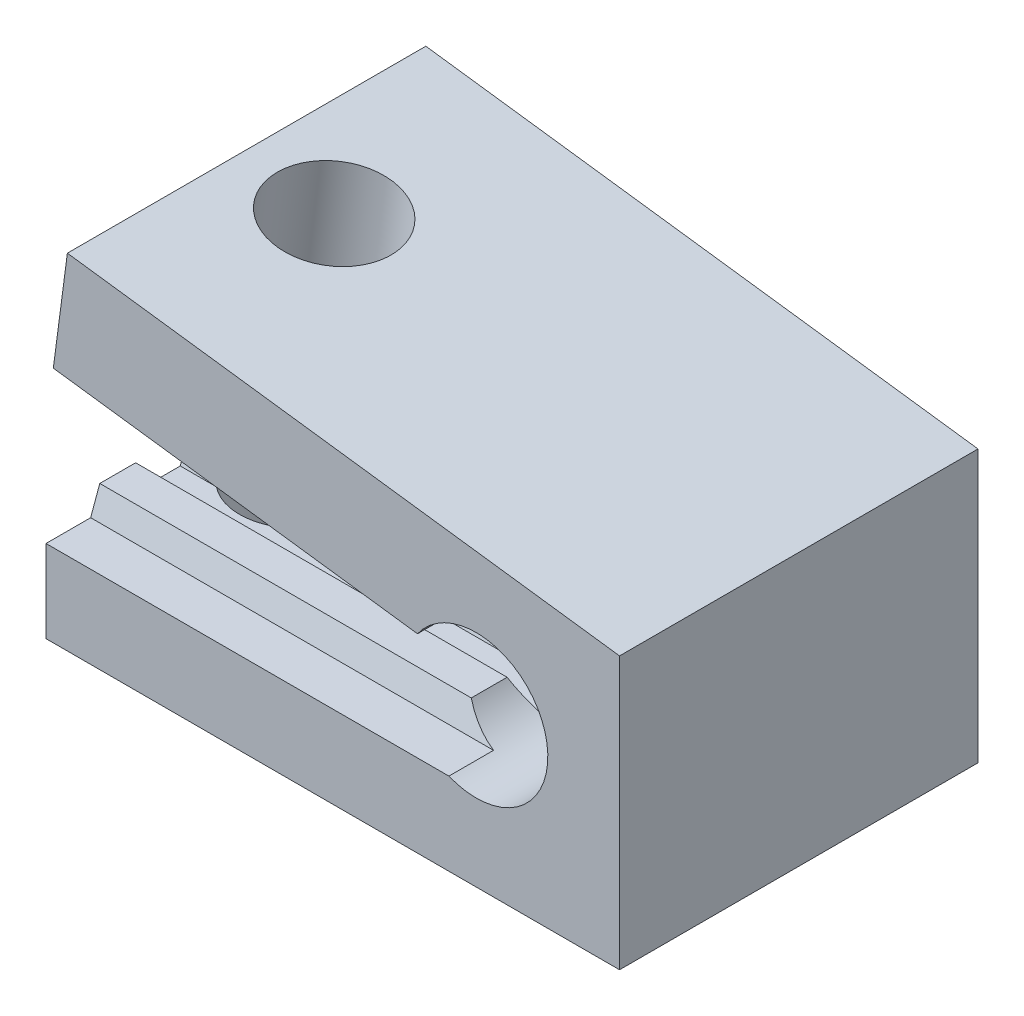
from build123d import *

# Parameters (mm, degrees)
BOSS_EXTRUDE1_DEPTH      = 5
CUT_EXTRUDE5_REACH       = 11.607
SKETCH4_R                = 1.6
CUT_EXTRUDE6_REACH       = 11.612
SKETCH5_R                = 1.6
CUT_EXTRUDE12_DEPTH      = 1
CUT_EXTRUDE12_DEPTH_BACK = 12


with BuildPart() as part:
    # Sketch1 → Boss-Extrude1 (new body, symmetric)
    with BuildSketch(Plane.XY):
        with BuildLine():
            Line((4, 6.083853012), (-11.403967093, 8.111823753))
            Line((-11.403967093, 8.111823753), (-11.795545669, 5.137489168))
            Line((-11.795545669, 5.137489168), (-1.636306817, 3.8))
            ThreePointArc((-1.636306817, 3.8), (2, 2.65), (-1.636306817, 1.5))
            Line((-1.636306817, 1.5), (-12, 1.5))
            Line((-12, 1.5), (-12, -1.5))
            Line((-12, -1.5), (4, -1.5))
            Line((4, -1.5), (4, 6.083853012))
        make_face()
    extrude(amount=BOSS_EXTRUDE1_DEPTH, both=True)

    # Sketch4 → Cut-Extrude5 (cut, up to next)
    with BuildSketch(Plane(origin=(0.855456861, 6.49783997, 0), x_dir=(0.991444861, -0.130526192, 0), z_dir=(0.130526192, 0.991444861, 0)), mode=Mode.PRIVATE) as cut_extrude5_sk1:
        with Locations((-9.9, 0)):
            Circle(SKETCH4_R)
    cut_extrude5_tool1 = extrude(cut_extrude5_sk1.sketch, amount=-CUT_EXTRUDE5_REACH, mode=Mode.PRIVATE) & part.part
    add(cut_extrude5_tool1.solids().sort_by_distance((-8.959847, 7.790049, 0))[0], mode=Mode.SUBTRACT)

    # Sketch5 → Cut-Extrude6 (cut, up to next)
    with BuildSketch(Plane.XZ.offset(1.5), mode=Mode.PRIVATE) as cut_extrude6_sk1:
        with Locations((-10, 0)):
            Circle(SKETCH5_R)
    cut_extrude6_tool1 = extrude(cut_extrude6_sk1.sketch, amount=-CUT_EXTRUDE6_REACH, mode=Mode.PRIVATE) & part.part
    add(cut_extrude6_tool1.solids().sort_by_distance((-10, -1.5, 0))[0], mode=Mode.SUBTRACT)

    # Sketch6 → Cut-Extrude12 (cut, two sides)
    with BuildSketch(Plane.ZY.offset(12)) as cut_extrude12_sk:
        Polygon((-2.5, 1.5), (-4, 1.5), (-3.745220836, 0.8), (-2.754779164, 0.8), align=None)
        Polygon((0, 1.5), (-1.5, 1.5), (-1.245220836, 0.8), (-0.254779164, 0.8), align=None)
        Polygon((3.754779164, 0.8), (5, 0.8), (5, 1.5), (3.5, 1.5), align=None)
        Polygon((2.5, 1.5), (1, 1.5), (1.254779164, 0.8), (2.245220836, 0.8), align=None)
    extrude(amount=CUT_EXTRUDE12_DEPTH, mode=Mode.SUBTRACT)
    extrude(cut_extrude12_sk.sketch, amount=-CUT_EXTRUDE12_DEPTH_BACK, mode=Mode.SUBTRACT)


solid = part.part
